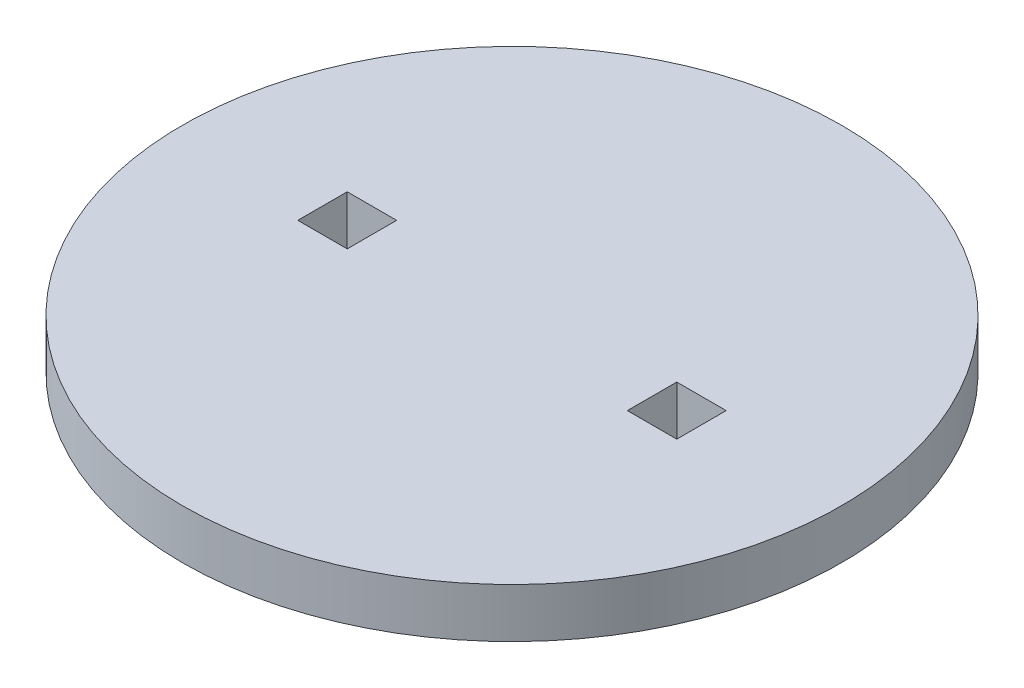
from build123d import *

# Parameters (mm, degrees)
CROQUIS1_R              = 40
CROQUIS1_W              = 6
CROQUIS1_H              = 6
SALIENTE_EXTRUIR1_DEPTH = 6


with BuildPart() as part:
    # Croquis1 → Saliente-Extruir1 (new body)
    with BuildSketch(Plane(origin=(0, 0, 0), x_dir=(1, 0, 0), z_dir=(0, 1, 0))):
        Circle(CROQUIS1_R)
        with Locations((-20, 0)):
            Rectangle(CROQUIS1_W, CROQUIS1_H, mode=Mode.SUBTRACT)
        with Locations((20, 0)):
            Rectangle(CROQUIS1_W, CROQUIS1_H, mode=Mode.SUBTRACT)
    extrude(amount=SALIENTE_EXTRUIR1_DEPTH)


solid = part.part
